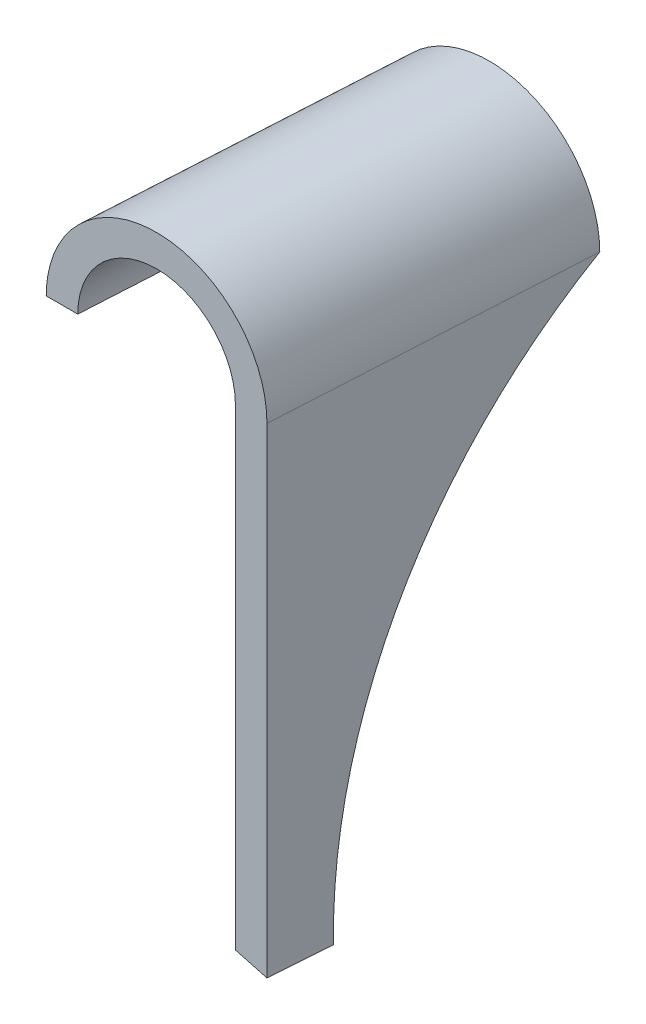
from build123d import *

# Parameters (mm, degrees)
SKETCH1_R               = 3.2639
BOSS_EXTRUDE1_DEPTH     = 10
SKETCH2_W               = 55.96454122
SKETCH2_H               = 39.556429901
BOSS_EXTRUDE2_DEPTH     = 50
CUT_EXTRUDE1_DEPTH      = 3.621876658
CUT_EXTRUDE1_DEPTH_BACK = 57.750909587
CUT_EXTRUDE3_DEPTH      = 104.020815944
BOSS_EXTRUDE3_REACH     = 105.021
SKETCH10_R              = 90
CUT_EXTRUDE4_DEPTH      = 50
CUT_EXTRUDE5_DEPTH      = 50


with BuildPart() as part:
    # Sketch1 → Boss-Extrude1 (new body)
    with BuildSketch(Plane.XY):
        with BuildLine():
            ThreePointArc((0, -23.8125), (-4.393398282, -34.419101718), (-15, -38.8125))
            Line((-15, -38.8125), (-119.778475404, -10.737192131))
            Line((-119.778475404, -10.737192131), (-119.778475404, 66.887807869))
            Line((-119.778475404, 66.887807869), (-15, 38.8125))
            ThreePointArc((-15, 38.8125), (-4.393398282, 34.419101718), (0, 23.8125))
            Line((0, 23.8125), (0, -23.8125))
        make_face()
        with Locations((-15, 23.8125)):
            Circle(SKETCH1_R, mode=Mode.SUBTRACT)
        with Locations((-15, -23.8125)):
            Circle(SKETCH1_R, mode=Mode.SUBTRACT)
    extrude(amount=BOSS_EXTRUDE1_DEPTH)

    # Sketch2 → Boss-Extrude2 (add)
    with BuildSketch(Plane.XY.offset(10)):
        with Locations((-137.760746014, 83.986530895)):
            Rectangle(SKETCH2_W, SKETCH2_H)
    extrude(amount=-BOSS_EXTRUDE2_DEPTH)

    # Sketch4 → Cut-Extrude1 (cut, two sides)
    with BuildSketch(Plane(origin=(-0.959208406, 0, 16.788657247), x_dir=(0, 1, 0), z_dir=(-0.057041289, 0, 0.99837182))) as cut_extrude1_sk:
        with BuildLine():
            ThreePointArc((64.208315944, 114.013041626), (81.708315944, 131.513041626), (64.208315944, 149.013041626))
            Line((64.208315944, 149.013041626), (64.208315944, 176.700065815))
            Line((64.208315944, 176.700065815), (111.984574651, 176.700065815))
            Line((111.984574651, 176.700065815), (111.984574651, 106.901315277))
            Line((111.984574651, 106.901315277), (64.208315944, 106.901315277))
            Line((64.208315944, 106.901315277), (64.208315944, 114.013041626))
        make_face()
        with BuildLine():
            Line((64.208315944, 144.013041626), (64.208315944, 119.013041626))
            ThreePointArc((64.208315944, 119.013041626), (76.708315944, 131.513041626), (64.208315944, 144.013041626))
        make_face()
    extrude(amount=CUT_EXTRUDE1_DEPTH, mode=Mode.SUBTRACT)
    extrude(cut_extrude1_sk.sketch, amount=-CUT_EXTRUDE1_DEPTH_BACK, mode=Mode.SUBTRACT)

    # Sketch7 → Cut-Extrude3 (cut, through all)
    with BuildSketch(Plane(origin=(0, 64.208315944, 0), x_dir=(1, 0, 0), z_dir=(0, 1, 0))):
        Polygon((-119.778475404, 0), (-119.207132269, 0), (-119.778475404, -10), align=None)
    extrude(amount=-CUT_EXTRUDE3_DEPTH, mode=Mode.SUBTRACT)

    # Boss-Extrude3: up to this face of the body (flat: up to its plane)
    boss_extrude3_end = Plane(part.part.faces().sort_by_distance((-67.246532084, -24.813083921, 5.004556479))[0])
    # Sketch8 → Boss-Extrude3 (add, up to the picked face)
    with BuildSketch(Plane.XZ.offset(-64.208315944), mode=Mode.PRIVATE) as boss_extrude3_sk1:
        Polygon((-119.207132269, 0), (-116.92175973, -40), (-111.913605554, -40), (-114.198978093, 0), align=None)
    boss_extrude3_tool1 = split(extrude(boss_extrude3_sk1.sketch, amount=BOSS_EXTRUDE3_REACH, mode=Mode.PRIVATE), bisect_by=boss_extrude3_end, keep=Keep.BOTH, mode=Mode.PRIVATE)
    add(boss_extrude3_tool1.solids().sort_by_distance((-115.560369, 64.208316, -20))[0])

    # Sketch10 → Cut-Extrude4 (cut)
    with BuildSketch(Plane(origin=(-113.827407897, 0, -6.503450805), x_dir=(0.057041289, 0, -0.99837182), z_dir=(0.99837182, 0, 0.057041289))):
        with Locations((83.472510719, -10.677332841)):
            Circle(SKETCH10_R)
    extrude(amount=-CUT_EXTRUDE4_DEPTH, mode=Mode.SUBTRACT)

    # Sketch13 → Cut-Extrude5 (cut)
    with BuildSketch(Plane(origin=(-0.959208406, 0, 16.788657247), x_dir=(0, 1, 0), z_dir=(-0.057041289, 0, 0.99837182))):
        Polygon((64.208315944, 114.013041626), (-14.406743592, 114.013041626), (-68.138706229, -11.161425168), (108.567056958, -47.624519159), align=None)
    extrude(amount=-CUT_EXTRUDE5_DEPTH, mode=Mode.SUBTRACT)


solid = part.part
